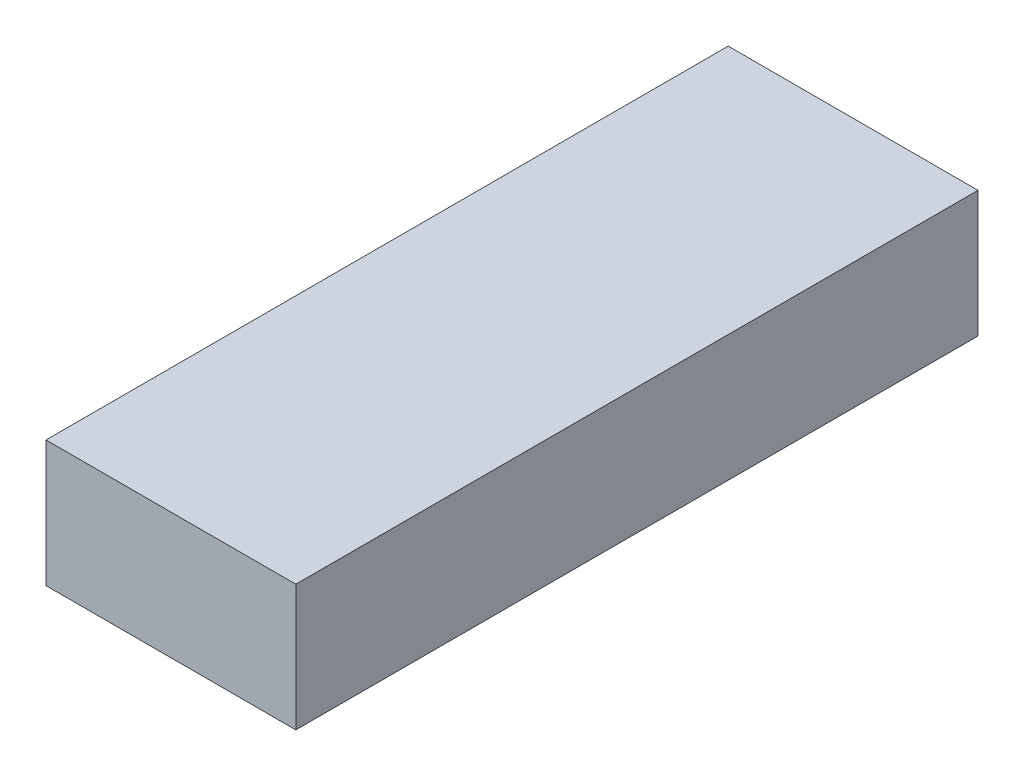
from build123d import *

# Parameters (mm, degrees)
SKETCH1_W           = 26
SKETCH1_H           = 71
BOSS_EXTRUDE1_DEPTH = 13.1318


with BuildPart() as part:
    # Sketch1 → Boss-Extrude1 (new body)
    with BuildSketch(Plane(origin=(0, 0, 0), x_dir=(1, 0, 0), z_dir=(0, 1, 0))):
        with Locations((13, 35.5)):
            Rectangle(SKETCH1_W, SKETCH1_H)
    extrude(amount=BOSS_EXTRUDE1_DEPTH)


solid = part.part
